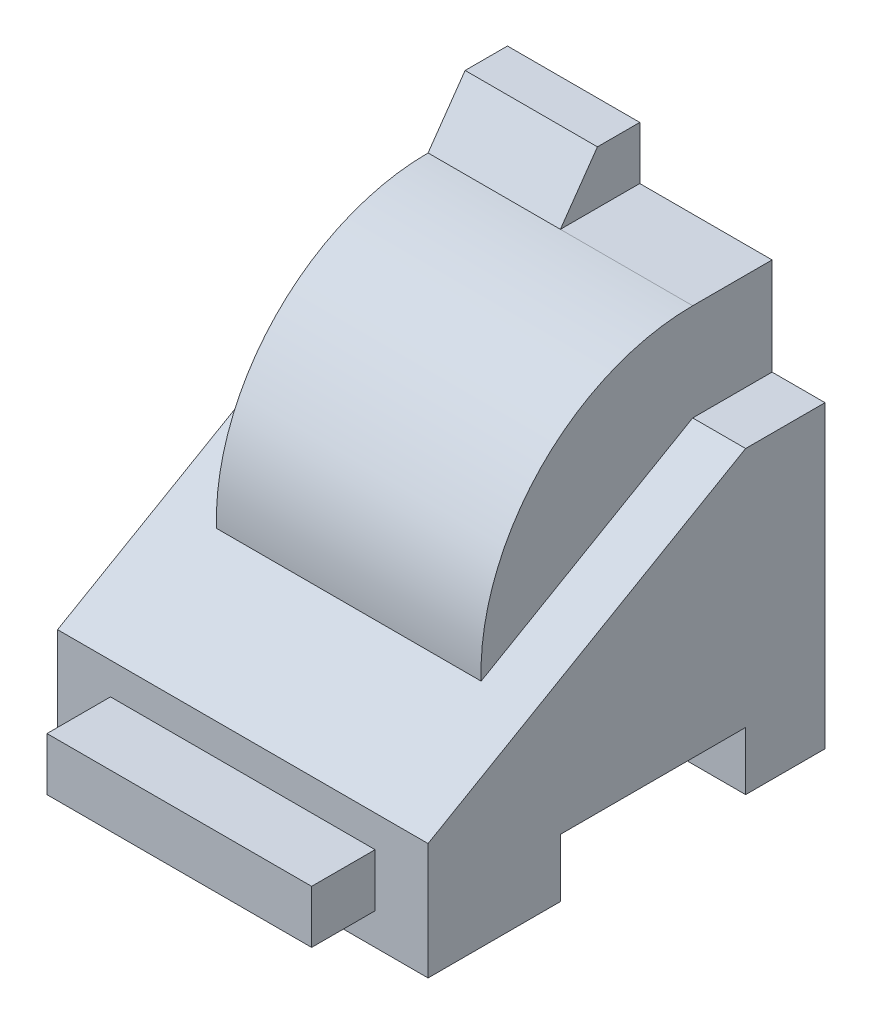
from build123d import *

# Parameters (mm, degrees)
BOSS_EXTRUDE1_DEPTH = 70
SKETCH2_W           = 50
SKETCH2_H           = 10
BOSS_EXTRUDE2_DEPTH = 12
BOSS_EXTRUDE3_DEPTH = 25
BOSS_EXTRUDE4_DEPTH = 25


with BuildPart() as part:
    # Sketch1 → Boss-Extrude1 (new body)
    with BuildSketch(Plane(origin=(0, 0, 0), x_dir=(0, 0, -1), z_dir=(1, 0, 0))):
        Polygon((0, 0), (0, 56.641016151), (-15, 56.641016151), (-75, 22), (-75, 0), (-50, 0), (-50, 11), (-15, 11), (-15, 0), align=None)
    extrude(amount=BOSS_EXTRUDE1_DEPTH)

    # Sketch2 → Boss-Extrude2 (add)
    with BuildSketch(Plane.XY.offset(75)):
        with Locations((35, 11)):
            Rectangle(SKETCH2_W, SKETCH2_H)
    extrude(amount=BOSS_EXTRUDE2_DEPTH)

    # Sketch3 → Boss-Extrude3 (add, symmetric)
    with BuildSketch(Plane(origin=(35, 0, 0), x_dir=(0, 0, -1), z_dir=(1, 0, 0))):
        with BuildLine():
            Line((-15, 75), (0, 75))
            Line((0, 75), (0, 56.641016151))
            Line((0, 56.641016151), (-15, 56.641016151))
            Line((-15, 56.641016151), (-54.974141253, 33.561934939))
            ThreePointArc((-54.974141253, 33.561934939), (-43.788214624, 62.771184684), (-15, 75))
        make_face()
    extrude(amount=BOSS_EXTRUDE3_DEPTH, both=True)

    # Sketch4 → Boss-Extrude4 (add)
    with BuildSketch(Plane(origin=(35, 0, 0), x_dir=(0, 0, -1), z_dir=(1, 0, 0))):
        Polygon((0, 75), (0, 85), (-8, 85), (-15, 75), align=None)
    extrude(amount=-BOSS_EXTRUDE4_DEPTH)


solid = part.part
